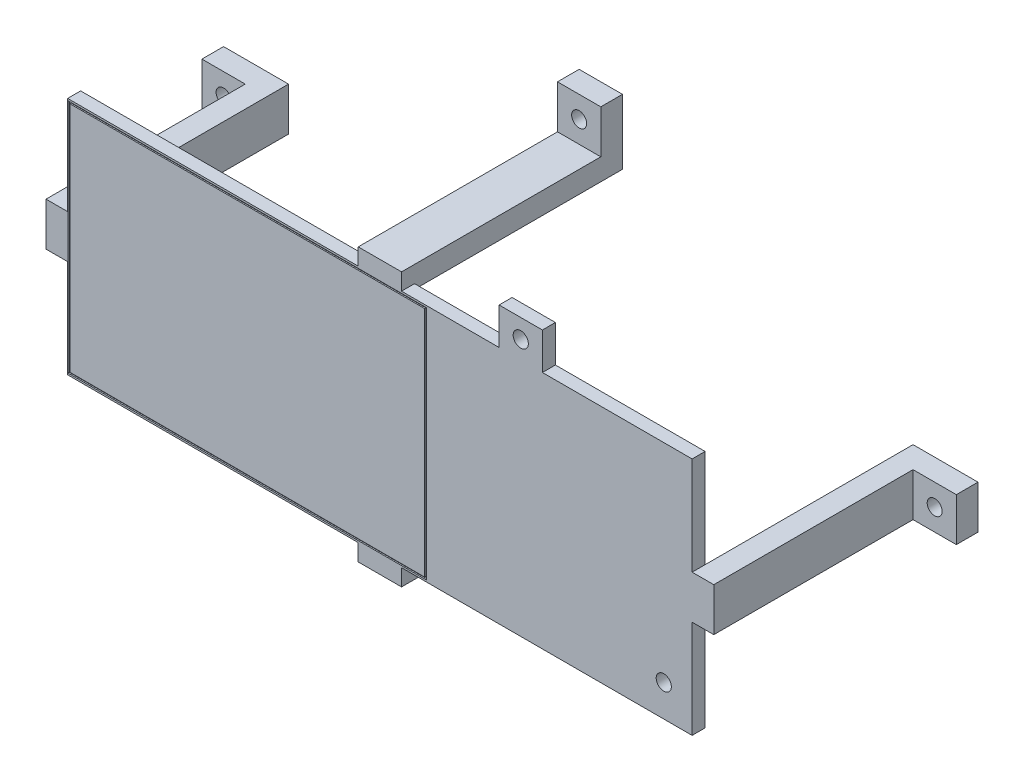
from build123d import *

# Parameters (mm, degrees)
SKETCH2_W             = 5
SKETCH2_H             = 10
BOSS_EXTRUDE1_DEPTH   = 48
SKETCH2_W_2           = 10
SKETCH2_H_2           = 5
BOSS_EXTRUDE1_2_DEPTH = 48
BOSS_EXTRUDE1_3_DEPTH = 48
BOSS_EXTRUDE1_4_DEPTH = 48
SKETCH3_W             = 165
SKETCH3_H             = 55.28
BOSS_EXTRUDE2_DEPTH   = 3
SKETCH4_W             = 10
SKETCH4_H             = 3.86
BOSS_EXTRUDE3_DEPTH   = 3
SKETCH5_W             = 10
SKETCH5_H             = 5
BOSS_EXTRUDE4_DEPTH   = 10
SKETCH7_W             = 5
SKETCH7_H             = 10
BOSS_EXTRUDE5_DEPTH   = 10
SKETCH8_R             = 1.73
CUT_EXTRUDE1_DEPTH    = 6
SKETCH10_W            = 10
SKETCH10_H            = 8.5
SKETCH10_W_2          = 1.85
SKETCH10_H_2          = 10
BOSS_EXTRUDE6_DEPTH   = 3
SKETCH11_R            = 1.75
CUT_EXTRUDE3_DEPTH    = 52
SKETCH12_W            = 82.72
SKETCH12_H            = 54.46
SKETCH12_W_2          = 81.92
SKETCH12_H_2          = 53.66
CUT_EXTRUDE4_DEPTH    = 0.28
CUT_EXTRUDE5_DEPTH    = 4


with BuildPart() as part:
    # Sketch2 → Boss-Extrude1 (new body)
    with BuildSketch(Plane.XY):
        with Locations((-74.585, 0)):
            Rectangle(SKETCH2_W, SKETCH2_H)
    extrude(amount=BOSS_EXTRUDE1_DEPTH)



with BuildPart() as body_2:
    # Sketch2 → Boss-Extrude1 2 (new body)
    with BuildSketch(Plane.XY):
        with Locations((0, 29)):
            Rectangle(SKETCH2_W_2, SKETCH2_H_2)
    extrude(amount=BOSS_EXTRUDE1_2_DEPTH)


with BuildPart() as body_3:
    # Sketch2 → Boss-Extrude1 3 (new body)
    with BuildSketch(Plane.XY):
        with Locations((74.585, 0)):
            Rectangle(SKETCH2_W, SKETCH2_H)
    extrude(amount=BOSS_EXTRUDE1_3_DEPTH)


with BuildPart() as body_4:
    # Sketch2 → Boss-Extrude1 4 (new body)
    with BuildSketch(Plane.XY):
        with Locations((0, -29)):
            Rectangle(SKETCH2_W_2, SKETCH2_H_2)
    extrude(amount=BOSS_EXTRUDE1_4_DEPTH)


with BuildPart() as part_1:
    add(part.part)

    add(body_2.part)  # Boss-Extrude2 merges body 2

    add(body_3.part)  # Boss-Extrude2 merges body 3

    add(body_4.part)  # Boss-Extrude2 merges body 4
    # Sketch3 → Boss-Extrude2 (add)
    with BuildSketch(Plane.XY.offset(48)):
        Rectangle(SKETCH3_W, SKETCH3_H)
    extrude(amount=BOSS_EXTRUDE2_DEPTH)

    # Sketch4 → Boss-Extrude3 (add)
    with BuildSketch(Plane.XY.offset(48)):
        with Locations((0, 29.57)):
            Rectangle(SKETCH4_W, SKETCH4_H)
        with Locations((0, -29.57)):
            Rectangle(SKETCH4_W, SKETCH4_H)
    extrude(amount=BOSS_EXTRUDE3_DEPTH)

    # Sketch5 → Boss-Extrude4 (add)
    with BuildSketch(Plane(origin=(0, 5, 0), x_dir=(1, 0, 0), z_dir=(0, 1, 0))):
        with Locations((-82.085, -2.5)):
            Rectangle(SKETCH5_W, SKETCH5_H)
        with Locations((82.085, -2.5)):
            Rectangle(SKETCH5_W, SKETCH5_H)
    extrude(amount=-BOSS_EXTRUDE4_DEPTH)

    # Sketch7 → Boss-Extrude5 (add)
    with BuildSketch(Plane.ZY.offset(5)):
        with Locations((2.5, 36.5)):
            Rectangle(SKETCH7_W, SKETCH7_H)
        with Locations((2.5, -36.5)):
            Rectangle(SKETCH7_W, SKETCH7_H)
    extrude(amount=-BOSS_EXTRUDE5_DEPTH)

    # Sketch8 → Cut-Extrude1 (cut, through all)
    with BuildSketch(Plane.XY.offset(5)):
        with Locations((-82.085, 0)):
            Circle(SKETCH8_R)
        with Locations((0, -36.5)):
            Circle(SKETCH8_R)
        with Locations((82.085, 0)):
            Circle(SKETCH8_R)
        with Locations((0, 36.5)):
            Circle(SKETCH8_R)
    extrude(amount=-CUT_EXTRUDE1_DEPTH, mode=Mode.SUBTRACT)

    # Sketch10 → Boss-Extrude6 (add)
    with BuildSketch(Plane.XY.offset(51)):
        with Locations((32.52, 31.89)):
            Rectangle(SKETCH10_W, SKETCH10_H)
        with Locations((69.005, -20.32)):
            Rectangle(SKETCH10_W_2, SKETCH10_H_2)
    extrude(amount=-BOSS_EXTRUDE6_DEPTH)

    # Sketch11 → Cut-Extrude3 (cut, through all)
    with BuildSketch(Plane.XY.offset(51)):
        with Locations((32.52, 31.75)):
            Circle(SKETCH11_R)
        with Locations((65.54, -20.32)):
            Circle(SKETCH11_R)
    extrude(amount=-CUT_EXTRUDE3_DEPTH, mode=Mode.SUBTRACT)

    # Sketch12 → Cut-Extrude4 (cut)
    with BuildSketch(Plane.XY.offset(51)):
        with Locations((-30.625, 0)):
            Rectangle(SKETCH12_W, SKETCH12_H)
        with Locations((-30.625, 0)):
            Rectangle(SKETCH12_W_2, SKETCH12_H_2, mode=Mode.SUBTRACT)
    extrude(amount=-CUT_EXTRUDE4_DEPTH, mode=Mode.SUBTRACT)

    # Sketch13 → Cut-Extrude5 (cut, through all)
    with BuildSketch(Plane(origin=(0, 0, 48), x_dir=(-1, 0, 0), z_dir=(0, 0, -1))):
        Polygon((82.5, -27.64), (82.5, 27.64), (72.085, 27.64), (72.085, 5), (77.085, 5), (77.085, -5), (72.085, -5), (72.085, -27.64), align=None)
        Polygon((-82.5, 27.64), (-82.5, -27.64), (-72.085, -27.64), (-72.085, -5), (-77.085, -5), (-77.085, 5), (-72.085, 5), (-72.085, 27.64), align=None)
    extrude(amount=-CUT_EXTRUDE5_DEPTH, mode=Mode.SUBTRACT)


solid = part_1.part
